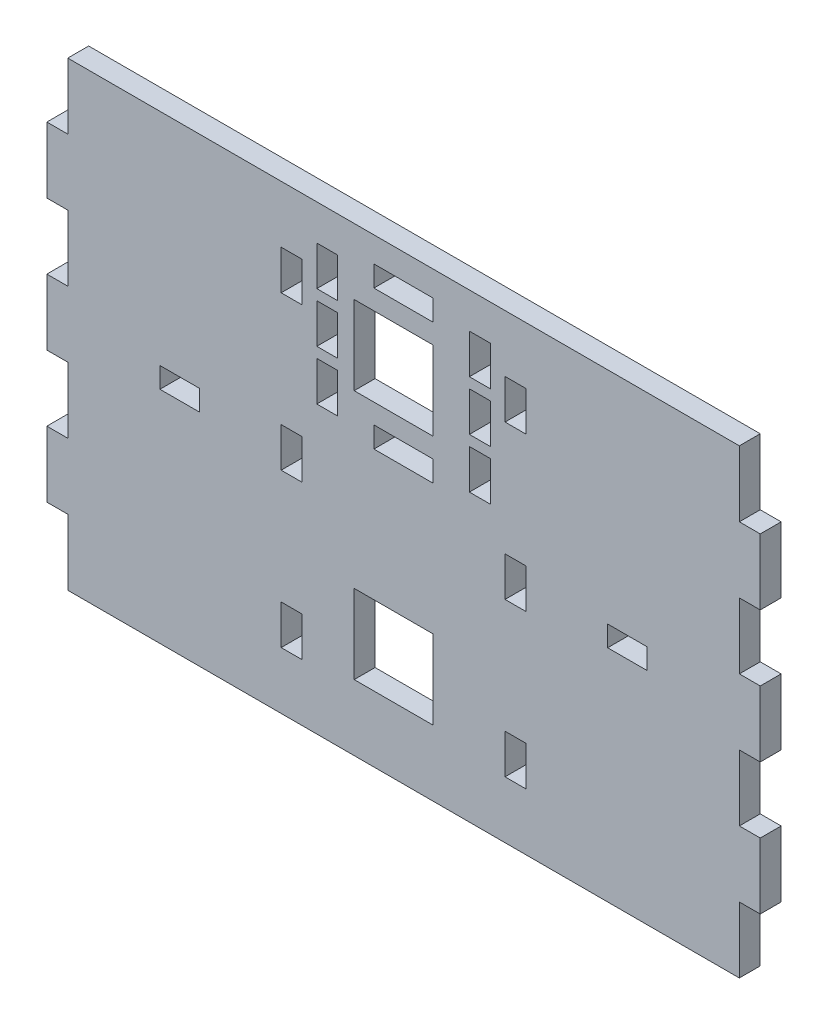
from build123d import *

# Parameters (mm, degrees)
SKETCH1_W           = 6
SKETCH1_H           = 3.125
SKETCH1_W_2         = 3.175
SKETCH1_H_2         = 6
BOSS_EXTRUDE1_DEPTH = 1.5875


with BuildPart() as part:
    # Sketch1 → Boss-Extrude1 (new body, symmetric)
    with BuildSketch(Plane.XY):
        Polygon((54.175, 0), (54.175, 5), (51, 5), (51, 15), (54.175, 15), (54.175, 25), (51, 25), (51, 35), (17, 35), (0, 35), (-17, 35), (-51, 35), (-51, 25), (-54.175, 25), (-54.175, 15), (-51, 15), (-51, 5), (-54.175, 5), (-54.175, -5), (-51, -5), (-51, -15), (-54.175, -15), (-54.175, -25), (-51, -25), (-51, -35), (0, -35), (51, -35), (51, -25), (54.175, -25), (54.175, -15), (51, -15), (51, -5), (54.175, -5), align=None)
        Polygon((-18.5875, -23.333333333), (-18.5875, -20.333333333), (-15.4125, -20.333333333), (-15.4125, -26.333333333), (-18.5875, -26.333333333), align=None, mode=Mode.SUBTRACT)
        Polygon((-7.5, -13), (0, -13), (4.5, -13), (4.5, -25), (0, -25), (-7.5, -25), align=None, mode=Mode.SUBTRACT)
        Polygon((18.5875, -20.333333333), (18.5875, -23.333333333), (18.5875, -26.333333333), (15.4125, -26.333333333), (15.4125, -20.333333333), align=None, mode=Mode.SUBTRACT)
        with Locations((-34, 0)):
            Rectangle(SKETCH1_W, SKETCH1_H, mode=Mode.SUBTRACT)
        with Locations((-17, 0)):
            Rectangle(SKETCH1_W_2, SKETCH1_H_2, mode=Mode.SUBTRACT)
        Polygon((-13.175, 14.4125), (-11.5875, 14.4125), (-10, 14.4125), (-10, 8.4125), (-13.175, 8.4125), align=None, mode=Mode.SUBTRACT)
        Polygon((-18.5875, 20.333333333), (-18.5875, 23.333333333), (-18.5875, 26.333333333), (-15.4125, 26.333333333), (-15.4125, 20.333333333), align=None, mode=Mode.SUBTRACT)
        Polygon((-10, 22), (-10, 19), (-10, 16), (-11.5875, 16), (-13.175, 16), (-13.175, 22), (-11.5875, 22), align=None, mode=Mode.SUBTRACT)
        Polygon((-7.5, 25), (0, 25), (4.5, 25), (4.5, 13), (0, 13), (-7.5, 13), align=None, mode=Mode.SUBTRACT)
        Polygon((-10, 23.5875), (-11.5875, 23.5875), (-13.175, 23.5875), (-13.175, 29.5875), (-10, 29.5875), align=None, mode=Mode.SUBTRACT)
        Polygon((-4.5, 6.825), (-4.5, 10), (0, 10), (4.5, 10), (4.5, 6.825), align=None, mode=Mode.SUBTRACT)
        with Locations((17, 0)):
            Rectangle(SKETCH1_W_2, SKETCH1_H_2, mode=Mode.SUBTRACT)
        Polygon((10, 14.4125), (11.5875, 14.4125), (13.175, 14.4125), (13.175, 8.4125), (10, 8.4125), align=None, mode=Mode.SUBTRACT)
        Polygon((37, 1.5625), (37, 0), (37, -1.5625), (31, -1.5625), (31, 1.5625), align=None, mode=Mode.SUBTRACT)
        Polygon((13.175, 16), (11.5875, 16), (10, 16), (10, 19), (10, 22), (11.5875, 22), (13.175, 22), align=None, mode=Mode.SUBTRACT)
        Polygon((18.5875, 23.333333333), (18.5875, 20.333333333), (15.4125, 20.333333333), (15.4125, 26.333333333), (18.5875, 26.333333333), align=None, mode=Mode.SUBTRACT)
        Polygon((-4.5, 31.175), (4.5, 31.175), (4.5, 28), (0, 28), (-4.5, 28), align=None, mode=Mode.SUBTRACT)
        Polygon((13.175, 23.5875), (11.5875, 23.5875), (10, 23.5875), (10, 29.5875), (13.175, 29.5875), align=None, mode=Mode.SUBTRACT)
    extrude(amount=BOSS_EXTRUDE1_DEPTH, both=True)


solid = part.part
